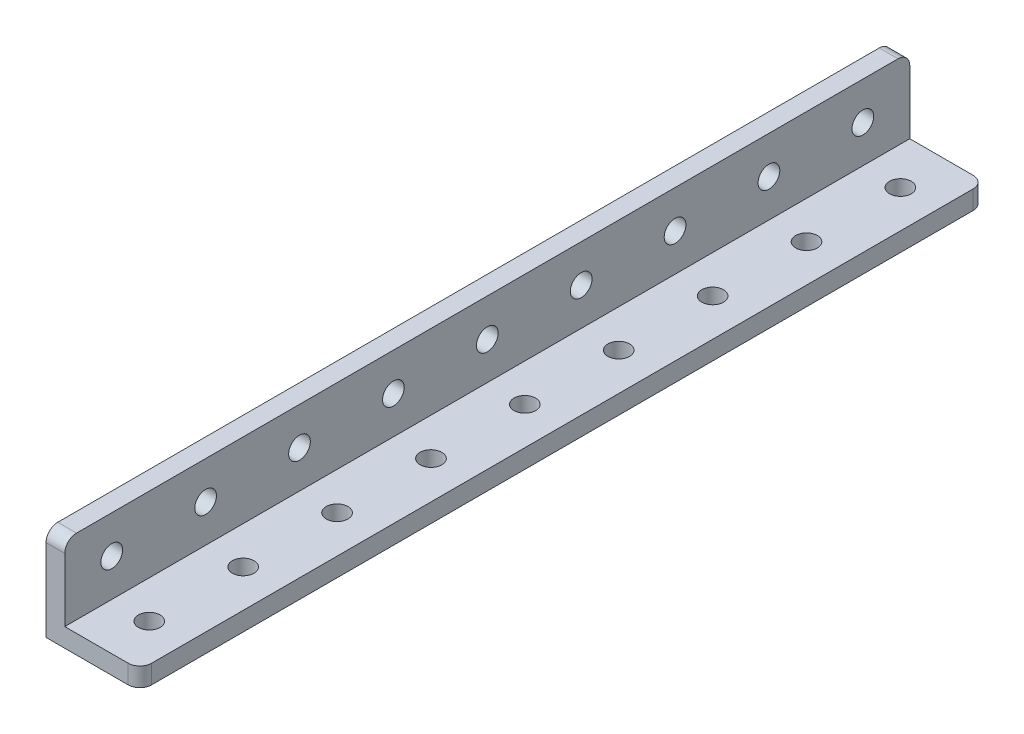
from build123d import *

# Parameters (mm, degrees)
EXTRUDE1_DEPTH      = 72
FILLET1_R           = 2
SKETCH2_R           = 1.85
CUT_EXTRUDE1_DEPTH  = 17
SKETCH3_R           = 1.85
CUT_EXTRUDE2_DEPTH  = 17
LPATTERN1_COUNT     = 5
LPATTERN1_PITCH     = 16
LPATTERN1_COL_COUNT = 5
LPATTERN1_COL_PITCH = 16


with BuildPart() as part:
    # Sketch1 → Extrude1 (new body, symmetric)
    with BuildSketch(Plane.XY):
        Polygon((0, 0), (16, 0), (16, 3.2), (3.2, 3.2), (3.2, 16), (0, 16), align=None)
    extrude(amount=EXTRUDE1_DEPTH, both=True)

    # Fillet1
    fillet1_edges = [part.edges().sort_by_distance(p)[0] for p in [
        (16, 1.6, -72),
        (1.6, 16, -72),
        (1.6, 16, 72),
        (16, 1.6, 72),
    ]]
    fillet(fillet1_edges, radius=FILLET1_R)

    # Sketch2 → Cut-Extrude1 (cut, through all)
    with BuildSketch(Plane.ZY):
        with Locations((0, 9.6)):
            Circle(SKETCH2_R)
    cut_extrude1 = extrude(amount=-CUT_EXTRUDE1_DEPTH, mode=Mode.SUBTRACT)

    # Sketch3 → Cut-Extrude2 (cut, through all)
    with BuildSketch(Plane.XZ):
        with Locations((9.6, 0)):
            Circle(SKETCH3_R)
    cut_extrude2 = extrude(amount=-CUT_EXTRUDE2_DEPTH, mode=Mode.SUBTRACT)

    # LPattern1: Cut-Extrude1, Cut-Extrude2 ×5
    with Locations(*[(0, 0, i * LPATTERN1_PITCH) for i in range(1, LPATTERN1_COUNT)]):
        add(cut_extrude1, mode=Mode.SUBTRACT)
        add(cut_extrude2, mode=Mode.SUBTRACT)

    # LPattern1 col: Cut-Extrude1, Cut-Extrude2 ×5
    with Locations(*[(0, 0, -i * LPATTERN1_COL_PITCH) for i in range(1, LPATTERN1_COL_COUNT)]):
        add(cut_extrude1, mode=Mode.SUBTRACT)
        add(cut_extrude2, mode=Mode.SUBTRACT)


solid = part.part
